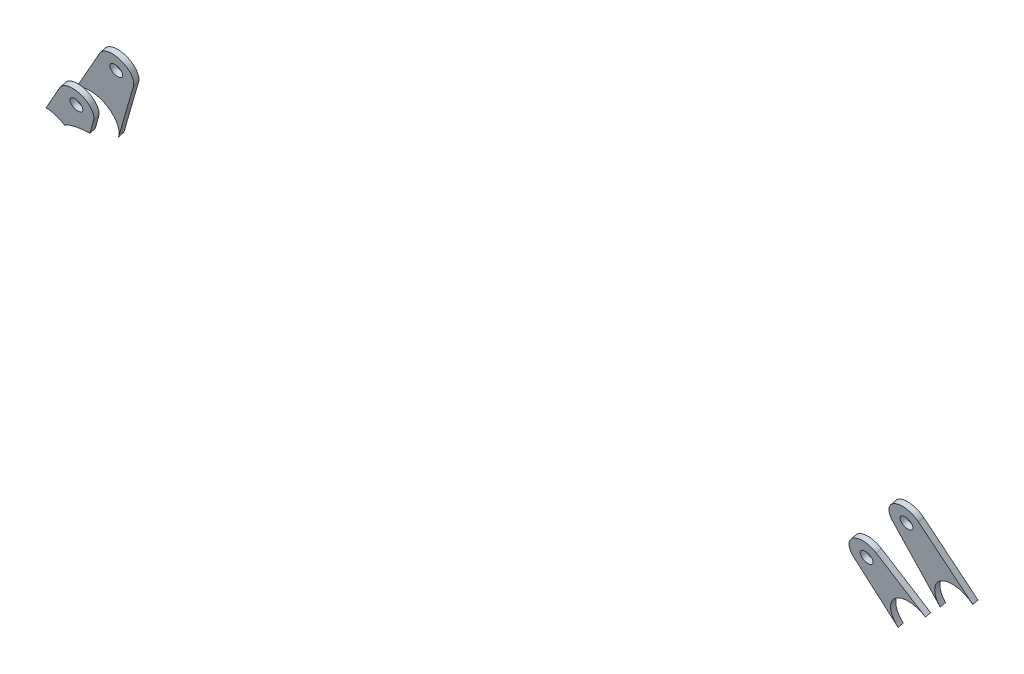
from build123d import *

# Parameters (mm, degrees)
SZKIC1_R                      = 3.5
DODANIE_WYCI_GNI_CIE1_DEPTH   = 3
DODANIE_WYCI_GNI_CIE1_2_DEPTH = 3
SZKIC2_R                      = 3.5
DODANIE_WYCI_GNI_CIE2_DEPTH   = 3
DODANIE_WYCI_GNI_CIE2_2_DEPTH = 3


with BuildPart() as part:
    # Szkic1 → Dodanie-wyciągnięcie1 (new body)
    with BuildSketch(Plane(origin=(0.734765672, -51.515766997, 211.89173064), x_dir=(-0.999994323, -0.000796009, 0.003274099), z_dir=(-0.003369474, 0.236239983, -0.971688899))):
        with BuildLine():
            Line((-187.169292625, 315.892999472), (-209.441296402, 282.035694004))
            add(Edge.make_bspline(
                [(-209.441296402, 282.035694004), (-206.775889814, 286.087573931), (-202.858683854, 287.758514493), (-199.168709849, 287.729320466)],
                knots=[0.829057948, 0.829057948, 0.829057948, 0.829057948, 1, 1, 1, 1], degree=3, weights=[0.550001273, 0.622077689, 0.772077264, 1]))
            add(Edge.make_bspline(
                [(-199.168709849, 287.729320466), (-190.501196179, 287.660745558), (-182.83338324, 279.699846229), (-188.063141669, 268.154847974)],
                knots=[0, 0, 0, 0, 0.307110013, 0.307110013, 0.307110013, 0.307110013], degree=3, weights=[1, 0.590519983, 0.432550792, 0.526092429]))
            Line((-188.063141669, 268.154847974), (-170.579009164, 306.752095248))
            ThreePointArc((-170.579009164, 306.752095248), (-174.648073701, 318.992665858), (-187.169292625, 315.892999472))
        make_face()
        with Locations((-179.232557038, 310.672058156)):
            Circle(SZKIC1_R, mode=Mode.SUBTRACT)
    extrude(amount=DODANIE_WYCI_GNI_CIE1_DEPTH)


with BuildPart() as body_2:
    # Szkic1 → Dodanie-wyci_gni_cie1 2 (new body)
    with BuildSketch(Plane(origin=(0.734765672, -51.515766997, 211.89173064), x_dir=(-0.999994323, -0.000796009, 0.003274099), z_dir=(-0.003369474, 0.236239983, -0.971688899))):
        with BuildLine():
            Line((252.09924571, 306.788563701), (269.495020667, 267.932859656))
            add(Edge.make_bspline(
                [(269.495020667, 267.932859656), (264.273580193, 279.595619508), (272.100198145, 287.545932005), (280.843848292, 287.476754726), (284.489311538, 287.447912856), (288.334102265, 285.754708593), (290.942104385, 281.750260367)],
                knots=[0.191302656, 0.191302656, 0.191302656, 0.191302656, 0.5, 0.5, 0.5, 0.669345632, 0.669345632, 0.669345632, 0.669345632], degree=3, weights=[0.527563025, 0.43092455, 0.588403542, 1, 0.774205824, 0.624886162, 0.552041016]))
            Line((290.942104385, 281.750260367), (268.730509404, 315.854980385))
            ThreePointArc((268.730509404, 315.854980385), (256.222848494, 319.011551058), (252.09924571, 306.788563701))
        make_face()
        with Locations((260.769940721, 310.670450874)):
            Circle(SZKIC1_R, mode=Mode.SUBTRACT)
    extrude(amount=DODANIE_WYCI_GNI_CIE1_2_DEPTH)


with BuildPart() as body_3:
    # Szkic2 → Dodanie-wyciągnięcie2 (new body)
    with BuildSketch(Plane(origin=(0.81226357, -56.949286615, 234.240575322), x_dir=(-0.999994323, -0.000796009, 0.003274099), z_dir=(-0.003369474, 0.236239983, -0.971688899))):
        with BuildLine():
            Line((-188.747219403, 276.500756835), (-171.097513803, 305.765830321))
            ThreePointArc((-171.097513803, 305.765830321), (-173.52348431, 318.265245141), (-186.204954965, 317.12462874))
            Line((-186.204954965, 317.12462874), (-208.005783592, 293.567497463))
            add(Edge.make_bspline(
                [(-208.005783592, 293.567497463), (-205.389239731, 296.394833446), (-202.143001596, 297.548854487), (-199.091211511, 297.52470959)],
                knots=[0.852820792, 0.852820792, 0.852820792, 0.852820792, 1, 1, 1, 1], degree=3, weights=[0.584576923, 0.665286698, 0.803761057, 1]))
            add(Edge.make_bspline(
                [(-199.091211511, 297.52470959), (-189.609209552, 297.449690681), (-181.643640554, 288.279239816), (-188.747219403, 276.500756835)],
                knots=[0, 0, 0, 0, 0.323520489, 0.323520489, 0.323520489, 0.323520489], degree=3, weights=[1, 0.568639348, 0.416386714, 0.543242099]))
        make_face()
        with Locations((-179.232557038, 310.672058156)):
            Circle(SZKIC2_R, mode=Mode.SUBTRACT)
    extrude(amount=DODANIE_WYCI_GNI_CIE2_DEPTH)


with BuildPart() as body_4:
    # Szkic2 → Dodanie-wyci_gni_cie2 2 (new body)
    with BuildSketch(Plane(origin=(0.81226357, -56.949286615, 234.240575322), x_dir=(-0.999994323, -0.000796009, 0.003274099), z_dir=(-0.003369474, 0.236239983, -0.971688899))):
        with BuildLine():
            add(Edge.make_bspline(
                [(271.544805537, 292.788325972), (273.893649928, 295.613268937), (277.150282954, 297.273295896), (280.832835711, 297.272503503)],
                knots=[0, 0, 0, 0, 0.553776247, 0.553776247, 0.553776247, 0.553776247], degree=3, weights=[1, 0.900443837, 0.856019513, 0.866727027]))
            Line((280.832835711, 297.272503503), (268.730509404, 315.854980385))
            ThreePointArc((268.730509404, 315.854980385), (256.222848494, 319.011551058), (252.09924571, 306.788563701))
            Line((252.09924571, 306.788563701), (256.412722699, 297.153857246))
            add(Edge.make_bspline(
                [(256.412722699, 297.153857246), (263.894698689, 296.768653735), (268.903557196, 295.098621506), (271.544805537, 292.788325972)],
                knots=[0.850046497, 0.850046497, 0.850046497, 0.850046497, 1, 1, 1, 1], degree=3, weights=[0.677755948, 0.73915615, 0.846570834, 1]))
        make_face()
        with Locations((260.769940721, 310.670450874)):
            Circle(SZKIC2_R, mode=Mode.SUBTRACT)
    extrude(amount=DODANIE_WYCI_GNI_CIE2_2_DEPTH)


solid = Compound([part.part, body_2.part, body_3.part, body_4.part])
